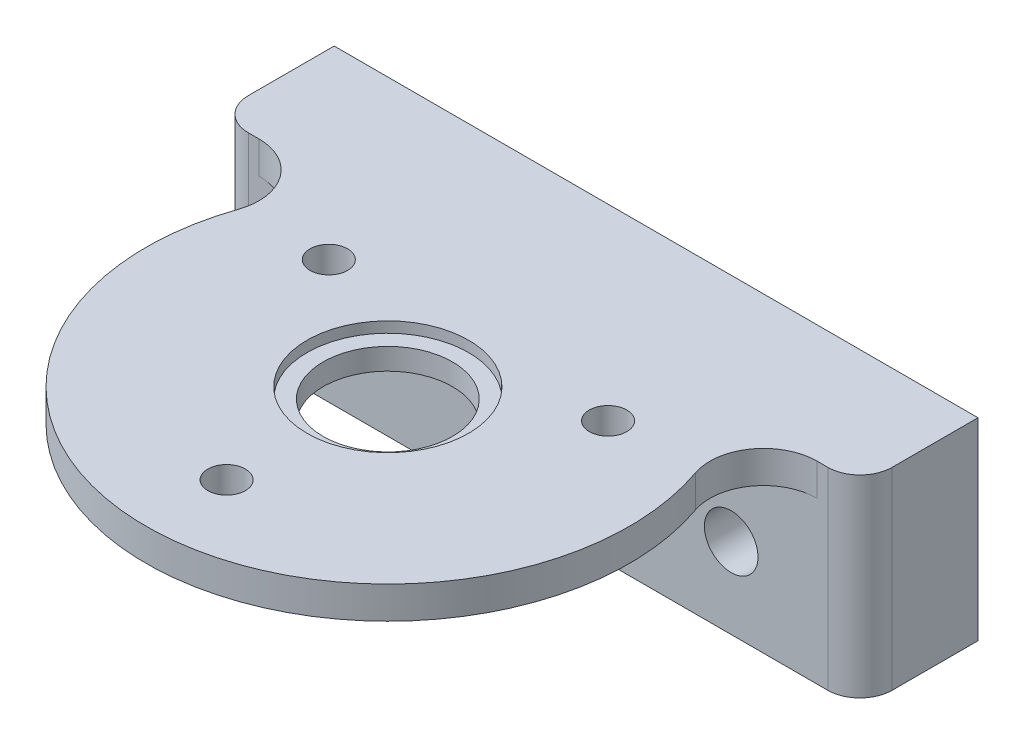
from build123d import *

# Parameters (mm, degrees)
SKETCH1_R                = 7.525
SKETCH1_R_2              = 6.025
BOSS_EXTRUDE1_DEPTH      = 2
SKETCH1_5_R              = 22.525
SKETCH1_5_R_2            = 7.525
BOSS_EXTRUDE3_DEPTH      = 3
SKETCH2_R                = 1.75
CUT_EXTRUDE1_DEPTH       = 4.5
CIRPATTERN1_COUNT        = 3
SKETCH9_W                = 60
SKETCH9_H                = 11
BOSS_EXTRUDE7_DEPTH      = 15
BOSS_EXTRUDE7_DEPTH_BACK = 3
CUT_EXTRUDE3_REACH       = 13
SKETCH10_R               = 2.5
FILLET4_R                = 3
FILLET5_R                = 5


with BuildPart() as part:
    # Sketch1 → Boss-Extrude1 (new body)
    with BuildSketch(Plane(origin=(0, 0, 0), x_dir=(1, 0, 0), z_dir=(0, 1, 0))):
        Circle(SKETCH1_R)
        Circle(SKETCH1_R_2, mode=Mode.SUBTRACT)
    extrude(amount=BOSS_EXTRUDE1_DEPTH)

    # Sketch1_5 → Boss-Extrude3 (add)
    with BuildSketch(Plane(origin=(0, 0, 0), x_dir=(1, 0, 0), z_dir=(0, 1, 0))):
        Circle(SKETCH1_5_R)
        Circle(SKETCH1_5_R_2, mode=Mode.SUBTRACT)
    extrude(amount=BOSS_EXTRUDE3_DEPTH)

    # Sketch2 → Cut-Extrude1 (cut)
    with BuildSketch(Plane(origin=(0, 3, 0), x_dir=(1, 0, 0), z_dir=(0, 1, 0))):
        with Locations((0, -15.025)):
            Circle(SKETCH2_R)
    cut_extrude1 = extrude(amount=-CUT_EXTRUDE1_DEPTH, mode=Mode.SUBTRACT)

    # CirPattern1: Cut-Extrude1 ×3 about axis
    cirpattern1_axis = Axis((0, 0, 0), (0, 1, 0))
    for i in range(1, CIRPATTERN1_COUNT):
        add(cut_extrude1.rotate(cirpattern1_axis, i * 360 / CIRPATTERN1_COUNT), mode=Mode.SUBTRACT)

    # Sketch9 → Boss-Extrude7 (add, two sides)
    with BuildSketch(Plane.XZ) as boss_extrude7_sk:
        with Locations((0, -19.5)):
            Rectangle(SKETCH9_W, SKETCH9_H)
    extrude(amount=BOSS_EXTRUDE7_DEPTH)
    extrude(boss_extrude7_sk.sketch, amount=-BOSS_EXTRUDE7_DEPTH_BACK)

    # Sketch10 → Cut-Extrude3 (cut, up to next)
    with BuildSketch(Plane.XY.offset(-14), mode=Mode.PRIVATE) as cut_extrude3_sk1:
        with Locations((-18, -7.5)):
            Circle(SKETCH10_R)
    cut_extrude3_tool1 = extrude(cut_extrude3_sk1.sketch, amount=-CUT_EXTRUDE3_REACH, mode=Mode.PRIVATE) & part.part
    add(cut_extrude3_tool1.solids().sort_by_distance((-18, -7.5, -14))[0], mode=Mode.SUBTRACT)
    # Sketch10 → Cut-Extrude3 (cut, up to next)
    with BuildSketch(Plane.XY.offset(-14), mode=Mode.PRIVATE) as cut_extrude3_sk2:
        with Locations((18, -7.5)):
            Circle(SKETCH10_R)
    cut_extrude3_tool2 = extrude(cut_extrude3_sk2.sketch, amount=-CUT_EXTRUDE3_REACH, mode=Mode.PRIVATE) & part.part
    add(cut_extrude3_tool2.solids().sort_by_distance((18, -7.5, -14))[0], mode=Mode.SUBTRACT)

    # Fillet4
    fillet4_edges = [part.edges().sort_by_distance(p)[0] for p in [
        (-30, -6, -14),
        (30, -6, -14),
    ]]
    fillet(fillet4_edges, radius=FILLET4_R)

    # Fillet5
    fillet5_edges = [part.edges().sort_by_distance(p)[0] for p in [
        (-17.645838745, 1.5, -14),
        (17.645838745, 1.5, -14),
    ]]
    fillet(fillet5_edges, radius=FILLET5_R)


solid = part.part
